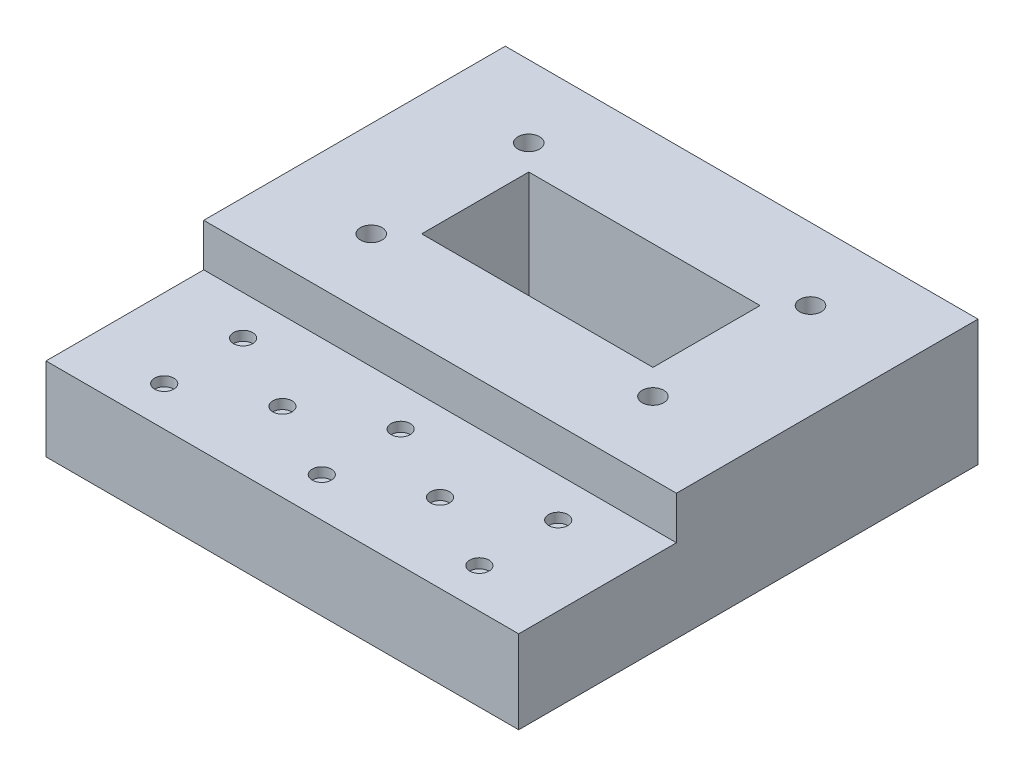
from build123d import *

# Parameters (mm, degrees)
SKETCH8_W           = 131.76
SKETCH8_H           = 95.69
SKETCH8_R           = 3.43
SKETCH8_W_2         = 73.4
SKETCH8_H_2         = 33.99
BOSS_EXTRUDE4_DEPTH = 40
SKETCH9_R           = 8
CUT_EXTRUDE2_DEPTH  = 8
SKETCH12_W          = 9.12
SKETCH12_H          = 95.69
BOSS_EXTRUDE5_DEPTH = 40
SKETCH13_W          = 150
SKETCH13_H          = 50.05
BOSS_EXTRUDE6_DEPTH = 26.38
SKETCH14_R          = 3.05
CUT_EXTRUDE3_DEPTH  = 3.05


with BuildPart() as part:
    # Sketch8 → Boss-Extrude4 (new body)
    with BuildSketch(Plane(origin=(0, 0, 0), x_dir=(1, 0, 0), z_dir=(0, 1, 0))):
        with Locations((-55.88, 37.845)):
            Rectangle(SKETCH8_W, SKETCH8_H)
        with Locations((-100.58, 12.85)):
            Circle(SKETCH8_R, mode=Mode.SUBTRACT)
        with Locations((-100.58, 62.84)):
            Circle(SKETCH8_R, mode=Mode.SUBTRACT)
        with Locations((-11.18, 62.84)):
            Circle(SKETCH8_R, mode=Mode.SUBTRACT)
        with Locations((-11.18, 12.85)):
            Circle(SKETCH8_R, mode=Mode.SUBTRACT)
        with Locations((-55.88, 37.845)):
            Rectangle(SKETCH8_W_2, SKETCH8_H_2, mode=Mode.SUBTRACT)
    extrude(amount=BOSS_EXTRUDE4_DEPTH)

    # Sketch9 → Cut-Extrude2 (cut)
    with BuildSketch(Plane.XZ):
        with Locations((-100.58, -12.85)):
            Circle(SKETCH9_R)
        with Locations((-11.18, -12.85)):
            Circle(SKETCH9_R)
        with Locations((-11.18, -62.84)):
            Circle(SKETCH9_R)
        with Locations((-100.58, -62.84)):
            Circle(SKETCH9_R)
    extrude(amount=-CUT_EXTRUDE2_DEPTH, mode=Mode.SUBTRACT)

    # Sketch12 → Boss-Extrude5 (add)
    with BuildSketch(Plane.XZ):
        with Locations((-126.32, -37.845)):
            Rectangle(SKETCH12_W, SKETCH12_H)
        with Locations((14.56, -37.845)):
            Rectangle(SKETCH12_W, SKETCH12_H)
    extrude(amount=-BOSS_EXTRUDE5_DEPTH)

    # Sketch13 → Boss-Extrude6 (add)
    with BuildSketch(Plane.XZ):
        with Locations((-55.88, 35.025)):
            Rectangle(SKETCH13_W, SKETCH13_H)
    extrude(amount=-BOSS_EXTRUDE6_DEPTH)

    # Sketch14 → Cut-Extrude3 (cut)
    with BuildSketch(Plane(origin=(0, 26.38, 0), x_dir=(1, 0, 0), z_dir=(0, 1, 0))):
        with Locations((-105.88, -22.5125)):
            Circle(SKETCH14_R)
        with Locations((-105.88, -47.5375)):
            Circle(SKETCH14_R)
        with BuildLine():
            ThreePointArc((-77.83, -35.025), (-80.88, -31.975), (-83.93, -35.025))
            Line((-83.93, -35.025), (-77.83, -35.025))
        make_face()
        with BuildLine():
            Line((-77.83, -35.025), (-83.93, -35.025))
            ThreePointArc((-83.93, -35.025), (-80.88, -38.075), (-77.83, -35.025))
        make_face()
        with BuildLine():
            ThreePointArc((-52.83, -22.5125), (-53.723324317, -20.355824317), (-55.88, -19.4625))
            Line((-55.88, -19.4625), (-55.88, -25.5625))
            ThreePointArc((-55.88, -25.5625), (-53.723324317, -24.669175683), (-52.83, -22.5125))
        make_face()
        with BuildLine():
            Line((-55.88, -25.5625), (-55.88, -19.4625))
            ThreePointArc((-55.88, -19.4625), (-58.93, -22.5125), (-55.88, -25.5625))
        make_face()
        with BuildLine():
            ThreePointArc((-55.88, -44.4875), (-58.93, -47.5375), (-55.88, -50.5875))
            Line((-55.88, -50.5875), (-55.88, -44.4875))
        make_face()
        with BuildLine():
            Line((-55.88, -44.4875), (-55.88, -50.5875))
            ThreePointArc((-55.88, -50.5875), (-53.723324317, -49.694175683), (-52.83, -47.5375))
            ThreePointArc((-52.83, -47.5375), (-53.723324317, -45.380824317), (-55.88, -44.4875))
        make_face()
        with BuildLine():
            ThreePointArc((-33.93, -35.025), (-33.036675683, -37.181675683), (-30.88, -38.075))
            Line((-30.88, -38.075), (-30.88, -35.025))
            Line((-30.88, -35.025), (-33.93, -35.025))
        make_face()
        with BuildLine():
            Line((-30.88, -35.025), (-30.88, -38.075))
            ThreePointArc((-30.88, -38.075), (-28.723324317, -37.181675683), (-27.83, -35.025))
            Line((-27.83, -35.025), (-30.88, -35.025))
        make_face()
        with BuildLine():
            ThreePointArc((-27.83, -35.025), (-28.723324317, -32.868324317), (-30.88, -31.975))
            Line((-30.88, -31.975), (-30.88, -35.025))
            Line((-30.88, -35.025), (-27.83, -35.025))
        make_face()
        with BuildLine():
            Line((-30.88, -35.025), (-30.88, -31.975))
            ThreePointArc((-30.88, -31.975), (-33.036675683, -32.868324317), (-33.93, -35.025))
            Line((-33.93, -35.025), (-30.88, -35.025))
        make_face()
        with BuildLine():
            ThreePointArc((-2.83, -22.5125), (-3.723324317, -20.355824317), (-5.88, -19.4625))
            Line((-5.88, -19.4625), (-5.88, -25.5625))
            ThreePointArc((-5.88, -25.5625), (-3.723324317, -24.669175683), (-2.83, -22.5125))
        make_face()
        with BuildLine():
            Line((-5.88, -25.5625), (-5.88, -19.4625))
            ThreePointArc((-5.88, -19.4625), (-8.93, -22.5125), (-5.88, -25.5625))
        make_face()
        with BuildLine():
            ThreePointArc((-5.88, -44.4875), (-8.93, -47.5375), (-5.88, -50.5875))
            Line((-5.88, -50.5875), (-5.88, -44.4875))
        make_face()
        with BuildLine():
            Line((-5.88, -44.4875), (-5.88, -50.5875))
            ThreePointArc((-5.88, -50.5875), (-3.723324317, -49.694175683), (-2.83, -47.5375))
            ThreePointArc((-2.83, -47.5375), (-3.723324317, -45.380824317), (-5.88, -44.4875))
        make_face()
    extrude(amount=-CUT_EXTRUDE3_DEPTH, mode=Mode.SUBTRACT)


solid = part.part
